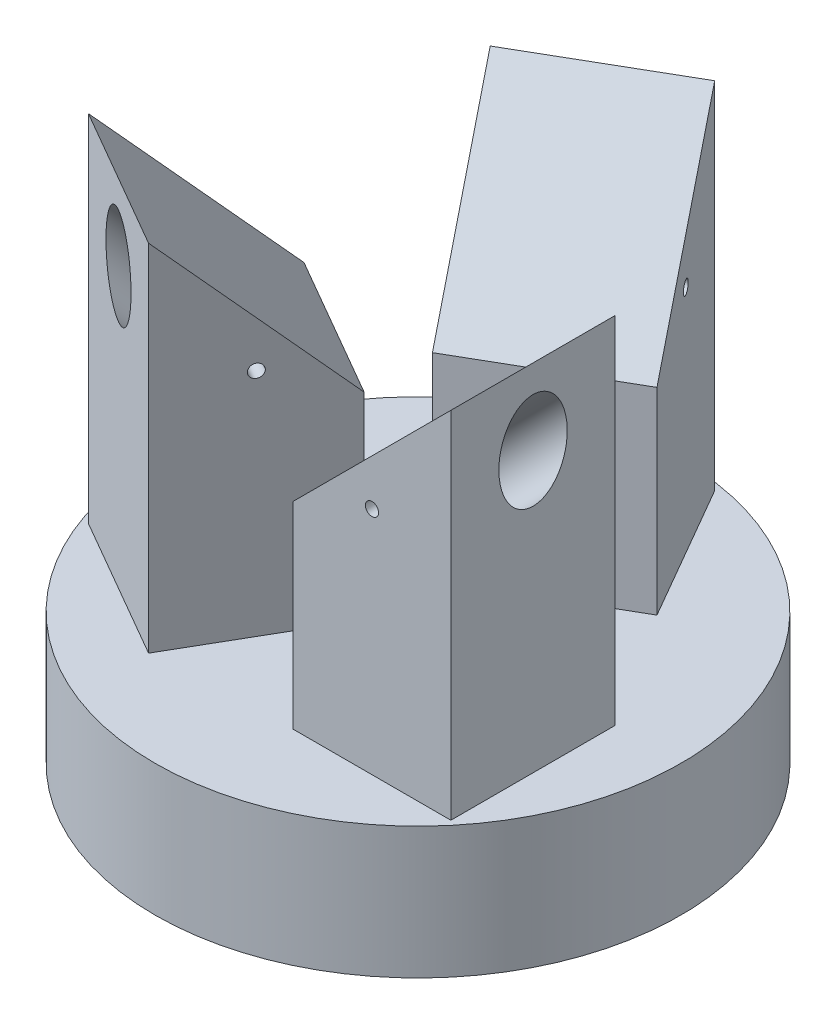
from build123d import *

# Parameters (mm, degrees)
SKETCH1_R           = 50.8
BOSS_EXTRUDE1_DEPTH = 25.4
BOSS_EXTRUDE2_DEPTH = 31.75
SKETCH9_R           = 6.604
CUT_EXTRUDE2_DEPTH  = 68.58
SKETCH10_R          = 1.27
CUT_EXTRUDE3_DEPTH  = 68.58
CIRPATTERN3_COUNT   = 3
SKETCH11_R          = 4.7625
CUT_EXTRUDE4_DEPTH  = 25.4


with BuildPart() as part:
    # Sketch1 → Boss-Extrude1 (new body)
    with BuildSketch(Plane(origin=(0, 0, 0), x_dir=(1, 0, 0), z_dir=(0, 1, 0))):
        Circle(SKETCH1_R)
    extrude(amount=BOSS_EXTRUDE1_DEPTH)

    # Sketch4 → Boss-Extrude2 (add)
    with BuildSketch(Plane.XY):
        Polygon((7.62, 25.4), (7.62, 63.5), (38.1, 93.98), (38.1, 25.4), align=None)
    boss_extrude2 = extrude(amount=BOSS_EXTRUDE2_DEPTH)

    # Sketch9 → Cut-Extrude2 (cut)
    with BuildSketch(Plane(origin=(66.802, 66.802, 0), x_dir=(0, 0, -1), z_dir=(0.707106781, 0.707106781, 0))):
        with Locations((-15.875, 29.160757667)):
            Circle(SKETCH9_R)
    cut_extrude2 = extrude(amount=-CUT_EXTRUDE2_DEPTH, mode=Mode.SUBTRACT)

    # Sketch10 → Cut-Extrude3 (cut)
    with BuildSketch(Plane.XY.offset(31.75)):
        with Locations((22.86, 69.85)):
            Circle(SKETCH10_R)
    cut_extrude3 = extrude(amount=-CUT_EXTRUDE3_DEPTH, mode=Mode.SUBTRACT)

    # CirPattern3: Boss-Extrude2, Cut-Extrude2, Cut-Extrude3 ×3 about axis
    cirpattern3_axis = Axis((0, 0, 0), (0, 1, 0))
    for i in range(1, CIRPATTERN3_COUNT):
        add(boss_extrude2.rotate(cirpattern3_axis, i * 360 / CIRPATTERN3_COUNT))
        add(cut_extrude2.rotate(cirpattern3_axis, i * 360 / CIRPATTERN3_COUNT), mode=Mode.SUBTRACT)
        add(cut_extrude3.rotate(cirpattern3_axis, i * 360 / CIRPATTERN3_COUNT), mode=Mode.SUBTRACT)

    # Sketch11 → Cut-Extrude4 (cut)
    with BuildSketch(Plane(origin=(0, 25.4, 0), x_dir=(1, 0, 0), z_dir=(0, 1, 0))):
        Circle(SKETCH11_R)
    extrude(amount=-CUT_EXTRUDE4_DEPTH, mode=Mode.SUBTRACT)


solid = part.part
